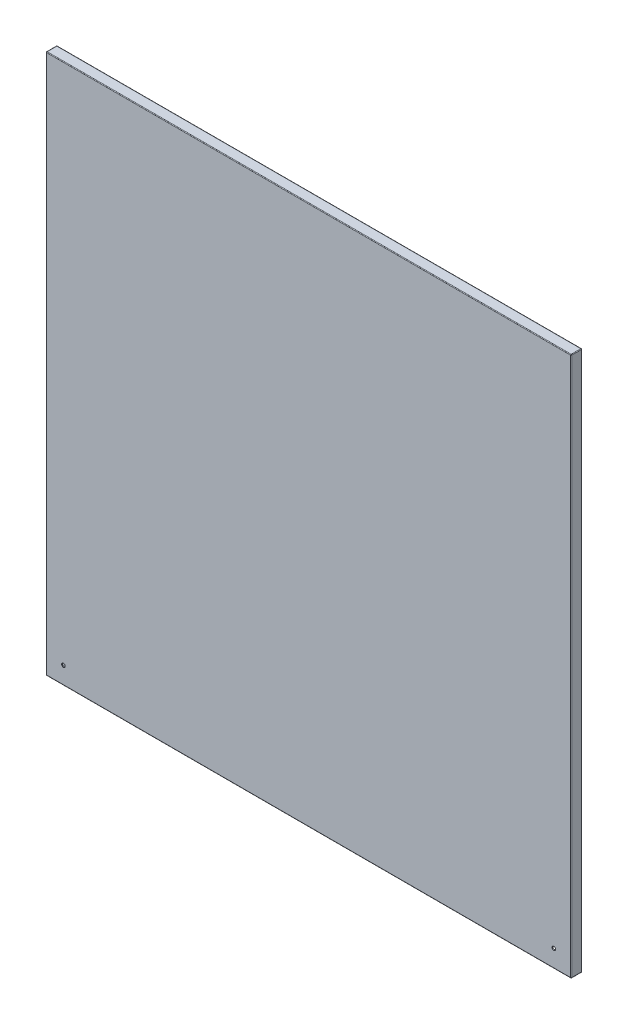
from build123d import *

# Parameters (mm, degrees)
SKETCH_1_W          = 875
SKETCH_1_H          = 900
EXTRUDE_1_DEPTH     = 1.5
SKETCH_2_W          = 875
SKETCH_2_H          = 900
SKETCH_2_W_2        = 872
SKETCH_2_H_2        = 897
EXTRUDE_2_DEPTH     = 15
SKETCH_3_W          = 875
SKETCH_3_H          = 900
SKETCH_3_W_2        = 845
SKETCH_3_H_2        = 880
EXTRUDE_3_DEPTH     = 1.5
SKETCH_6_R          = 3
CUT_EXTRUDE_1_DEPTH = 19
FILLET_1_R          = 1


with BuildPart() as part:
    # 草图1 → 凸台-拉伸1 (new body)
    with BuildSketch(Plane.XY):
        Rectangle(SKETCH_1_W, SKETCH_1_H)
    extrude(amount=EXTRUDE_1_DEPTH)

    # 草图2 → 凸台-拉伸2 (add)
    with BuildSketch(Plane(origin=(0, 0, 0), x_dir=(-1, 0, 0), z_dir=(0, 0, -1))):
        Rectangle(SKETCH_2_W, SKETCH_2_H)
        Rectangle(SKETCH_2_W_2, SKETCH_2_H_2, mode=Mode.SUBTRACT)
    extrude(amount=EXTRUDE_2_DEPTH)

    # 草图3 → 凸台-拉伸3 (add)
    with BuildSketch(Plane(origin=(0, 0, -15), x_dir=(-1, 0, 0), z_dir=(0, 0, -1))):
        Rectangle(SKETCH_3_W, SKETCH_3_H)
        Rectangle(SKETCH_3_W_2, SKETCH_3_H_2, mode=Mode.SUBTRACT)
    extrude(amount=EXTRUDE_3_DEPTH)

    # 草图6 → 切除-拉伸1 (cut, through all)
    with BuildSketch(Plane.XY.offset(1.5)):
        with Locations((-408.5, -421)):
            Circle(SKETCH_6_R)
        with Locations((408.5, -421)):
            Circle(SKETCH_6_R)
    extrude(amount=-CUT_EXTRUDE_1_DEPTH, mode=Mode.SUBTRACT)

    # 圆角1
    fillet_1_edges = [part.edges().sort_by_distance(p)[0] for p in [
        (437.5, 0, 1.5),
        (0, 450, 1.5),
        (-437.5, 0, -16.5),
        (0, 450, -16.5),
        (437.5, 0, -16.5),
        (0, -450, -16.5),
        (-437.5, 0, 1.5),
        (0, -450, 1.5),
        (-437.5, 450, -7.5),
        (437.5, 450, -7.5),
        (437.5, -450, -7.5),
        (-437.5, -450, -7.5),
    ]]
    fillet(fillet_1_edges, radius=FILLET_1_R)


solid = part.part
